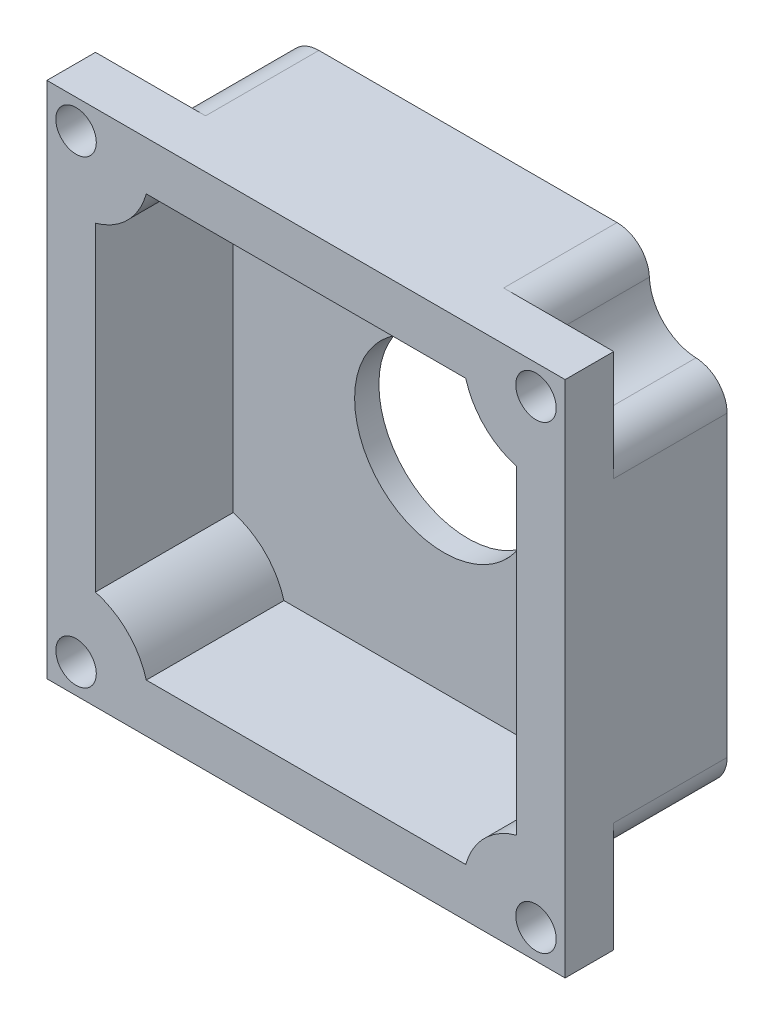
from build123d import *

# Parameters (mm, degrees)
SKETCH1_W           = 32
SKETCH1_H           = 32
SKETCH1_W_2         = 26
SKETCH1_H_2         = 26
BOSS_EXTRUDE1_DEPTH = 10
SKETCH2_W           = 26
SKETCH2_H           = 26
BOSS_EXTRUDE2_DEPTH = 1.5
SKETCH3_R           = 5.5
CUT_EXTRUDE1_DEPTH  = 9.5
SKETCH4_R           = 1.25
CUT_EXTRUDE2_DEPTH  = 21.5
SKETCH6_R           = 3
CUT_EXTRUDE3_DEPTH  = 7
SKETCH7_R           = 1.25
BOSS_EXTRUDE3_DEPTH = 3
CIRPATTERN1_COUNT   = 4
BOSS_EXTRUDE4_DEPTH = 8.5
CIRPATTERN2_COUNT   = 4
FILLET1_R           = 2


with BuildPart() as part:
    # Sketch1 → Boss-Extrude1 (new body)
    with BuildSketch(Plane.XY):
        Rectangle(SKETCH1_W, SKETCH1_H)
        Rectangle(SKETCH1_W_2, SKETCH1_H_2, mode=Mode.SUBTRACT)
    extrude(amount=BOSS_EXTRUDE1_DEPTH)

    # Sketch2 → Boss-Extrude2 (add)
    with BuildSketch(Plane(origin=(0, 0, 0), x_dir=(-1, 0, 0), z_dir=(0, 0, -1))):
        Rectangle(SKETCH2_W, SKETCH2_H)
    extrude(amount=-BOSS_EXTRUDE2_DEPTH)

    # Sketch3 → Cut-Extrude1 (cut)
    with BuildSketch(Plane(origin=(0, 0, 0), x_dir=(-1, 0, 0), z_dir=(0, 0, -1))):
        Circle(SKETCH3_R)
    extrude(amount=-CUT_EXTRUDE1_DEPTH, mode=Mode.SUBTRACT)

    # Sketch4 → Cut-Extrude2 (cut)
    with BuildSketch(Plane(origin=(0, 0, 0), x_dir=(-1, 0, 0), z_dir=(0, 0, -1))):
        with Locations((-14.2, 14.2)):
            Circle(SKETCH4_R)
        with Locations((14.2, 14.2)):
            Circle(SKETCH4_R)
        with Locations((14.2, -14.2)):
            Circle(SKETCH4_R)
        with Locations((-14.2, -14.2)):
            Circle(SKETCH4_R)
    extrude(amount=-CUT_EXTRUDE2_DEPTH, mode=Mode.SUBTRACT)

    # Sketch6 → Cut-Extrude3 (cut)
    with BuildSketch(Plane(origin=(0, 0, 0), x_dir=(-1, 0, 0), z_dir=(0, 0, -1))):
        with Locations((-14.2, 14.2)):
            Circle(SKETCH6_R)
        with Locations((14.2, 14.2)):
            Circle(SKETCH6_R)
        with Locations((14.2, -14.2)):
            Circle(SKETCH6_R)
        with Locations((-14.2, -14.2)):
            Circle(SKETCH6_R)
    extrude(amount=-CUT_EXTRUDE3_DEPTH, mode=Mode.SUBTRACT)

    # Sketch7 → Boss-Extrude3 (add)
    with BuildSketch(Plane(origin=(0, 0, 7), x_dir=(-1, 0, 0), z_dir=(0, 0, -1))):
        with BuildLine():
            ThreePointArc((11.8, 16), (11.220158645, 14.54719663), (11.450454583, 13))
            Line((11.450454583, 13), (13, 13))
            Line((13, 13), (13, 11.450454583))
            ThreePointArc((13, 11.450454583), (14.54719663, 11.220158645), (16, 11.8))
            Line((16, 11.8), (16, 16))
            Line((16, 16), (11.8, 16))
        make_face()
        with Locations((14.2, 14.2)):
            Circle(SKETCH7_R, mode=Mode.SUBTRACT)
        with BuildLine():
            Line((13, 13), (11.450454583, 13))
            ThreePointArc((11.450454583, 13), (12.078679656, 12.078679656), (13, 11.450454583))
            Line((13, 11.450454583), (13, 13))
        make_face()
    boss_extrude3 = extrude(amount=-BOSS_EXTRUDE3_DEPTH)

    # CirPattern1: Boss-Extrude3 ×4 about axis
    cirpattern1_axis = Axis((0, 0, 9.5), (0, 0, -1))
    for i in range(1, CIRPATTERN1_COUNT):
        add(boss_extrude3.rotate(cirpattern1_axis, i * 360 / CIRPATTERN1_COUNT))

    # Sketch8 → Boss-Extrude4 (add)
    with BuildSketch(Plane.XY.offset(1.5)):
        with BuildLine():
            ThreePointArc((-11.450454583, 13), (-12.078679656, 12.078679656), (-13, 11.450454583))
            Line((-13, 11.450454583), (-13, 9.862950312))
            ThreePointArc((-13, 9.862950312), (-11.018019485, 11.018019485), (-9.862950312, 13))
            Line((-9.862950312, 13), (-11.450454583, 13))
        make_face()
    boss_extrude4 = extrude(amount=BOSS_EXTRUDE4_DEPTH)

    # CirPattern2: Boss-Extrude4 ×4 about axis
    cirpattern2_axis = Axis((0, 0, 0), (0, 0, 1))
    for i in range(1, CIRPATTERN2_COUNT):
        add(boss_extrude4.rotate(cirpattern2_axis, i * 360 / CIRPATTERN2_COUNT))

    # Fillet1
    fillet1_edges = [part.edges().sort_by_distance(p)[0] for p in [
        (-16, -11.8, 3.5),
        (-11.8, -16, 3.5),
        (-16, 11.8, 3.5),
        (-11.8, 16, 3.5),
        (16, 11.8, 3.5),
        (11.8, 16, 3.5),
        (11.8, -16, 3.5),
        (16, -11.8, 3.5),
    ]]
    fillet(fillet1_edges, radius=FILLET1_R)


solid = part.part
